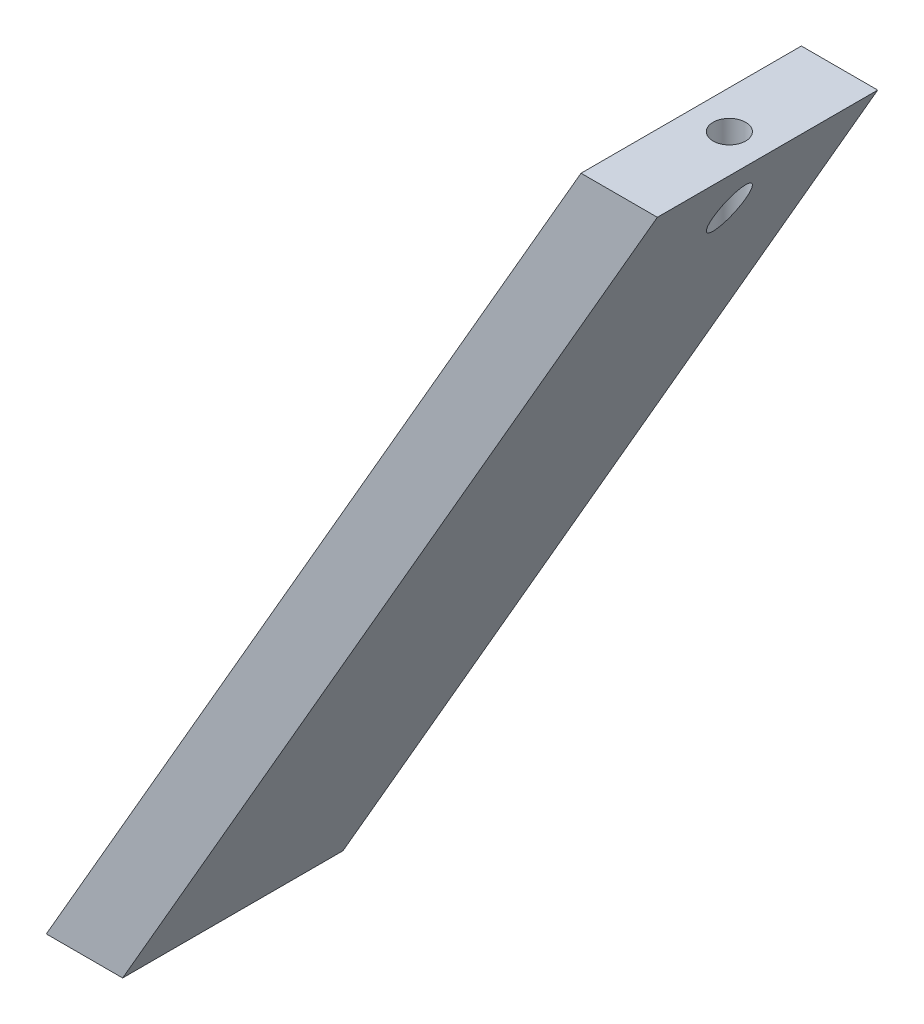
from build123d import *

# Parameters (mm, degrees)
LEFT_EXT_DEPTH = 63.5
HOLE_R         = 4.699
HOLE_CUT_DEPTH = 286.961588331


with BuildPart() as part:
    # Left → left_ext (new body)
    with BuildSketch(Plane.XY):
        Polygon((-165.1, 19.05), (-10.998522627, 285.961588331), (10.998522629, 285.961588331), (-143.102954744, 19.05), align=None)
    extrude(amount=LEFT_EXT_DEPTH)

    # hole → hole_cut (cut, through all)
    with BuildSketch(Plane(origin=(0, 0, 0), x_dir=(1, 0, 0), z_dir=(0, 1, 0))):
        with Locations((0, -31.75)):
            Circle(HOLE_R)
    extrude(amount=HOLE_CUT_DEPTH, mode=Mode.SUBTRACT)


solid = part.part
